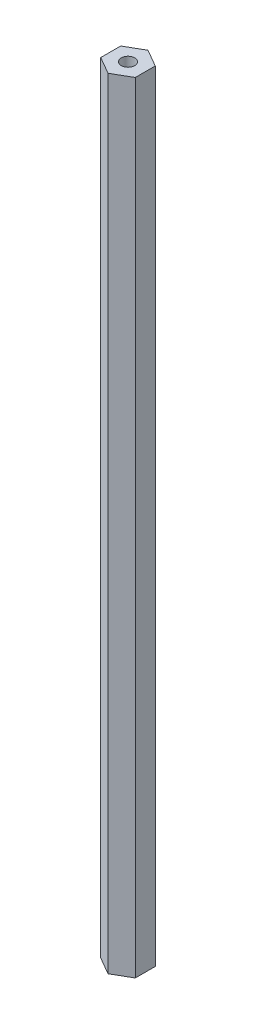
from build123d import *

# Parameters (mm, degrees)
BOSS_EXTRUDE1_DEPTH = 286.639
SKETCH2_R           = 2.4892
CUT_EXTRUDE1_DEPTH  = 25.4
SKETCH3_R           = 2.4892
CUT_EXTRUDE2_DEPTH  = 25.4


with BuildPart() as part:
    # Sketch1 → Boss-Extrude1 (new body)
    with BuildSketch(Plane(origin=(0, 0, 0), x_dir=(1, 0, 0), z_dir=(0, 1, 0))):
        Polygon((0, 7.332348419), (-6.35, 3.666174209), (-6.35, -3.666174209), (0, -7.332348419), (6.35, -3.666174209), (6.35, 3.666174209), align=None)
    extrude(amount=BOSS_EXTRUDE1_DEPTH)

    # Sketch2 → Cut-Extrude1 (cut)
    with BuildSketch(Plane(origin=(0, 286.639, 0), x_dir=(1, 0, 0), z_dir=(0, 1, 0))):
        Circle(SKETCH2_R)
    extrude(amount=-CUT_EXTRUDE1_DEPTH, mode=Mode.SUBTRACT)

    # Sketch3 → Cut-Extrude2 (cut)
    with BuildSketch(Plane(origin=(0, 0, 0), x_dir=(-1, 0, 0), z_dir=(0, -1, 0))):
        Circle(SKETCH3_R)
    extrude(amount=-CUT_EXTRUDE2_DEPTH, mode=Mode.SUBTRACT)


solid = part.part
